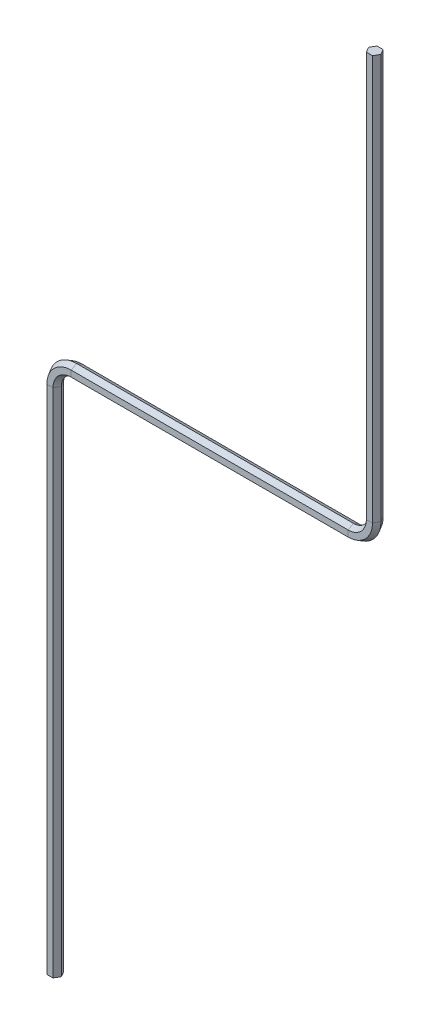
from build123d import *


with BuildPart() as part:
    # Sweep3: sweep along a path in Sketch2
    with BuildLine(Plane.XY) as sweep3_path:
        Line((0, 0), (0, 480))
        ThreePointArc((0, 480), (5.857864376, 494.142135624), (20, 500))
        Line((20, 500), (280, 500))
        ThreePointArc((280, 500), (294.142135624, 505.857864376), (300, 520))
        Line((300, 520), (300, 900))
    # Sketch3 → Sweep3 (sweep)
    with BuildSketch(Plane(origin=(0, 0, 0), x_dir=(1, 0, 0), z_dir=(0, 1, 0))):
        Polygon((2.886751346, 5), (-2.886751346, 5), (-5.773502692, 0), (-2.886751346, -5), (2.886751346, -5), (5.773502692, 0), align=None)
    sweep(path=sweep3_path.line)


solid = part.part
